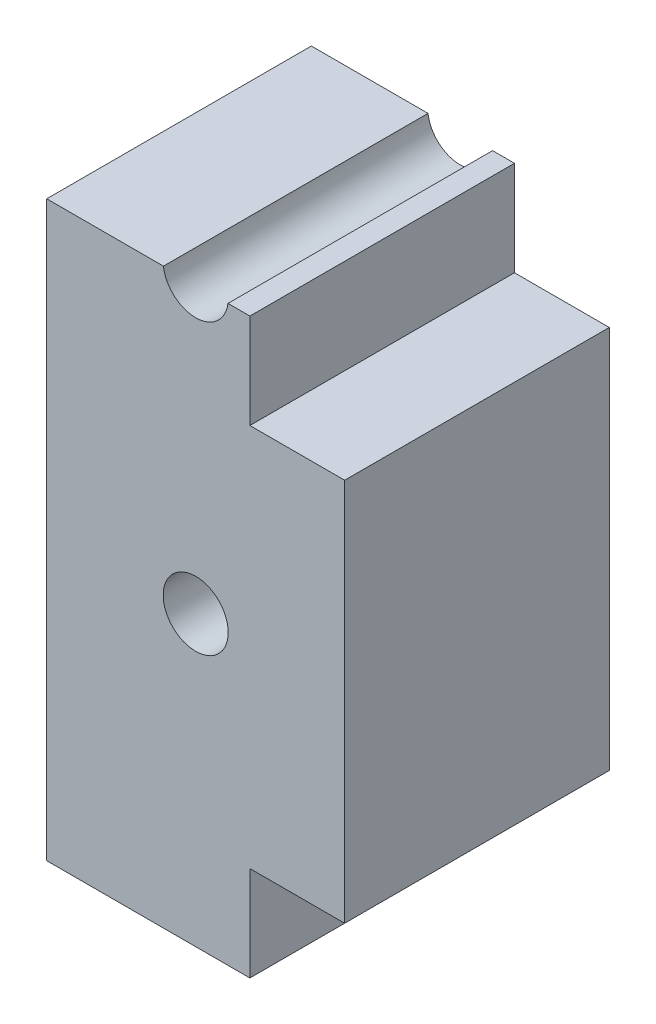
from build123d import *

# Parameters (mm, degrees)
SKETCH2_W           = 16.5
SKETCH2_H           = 31.75
BOSS_EXTRUDE1_DEPTH = 14.655
SKETCH5_W           = 5.25
SKETCH5_H           = 5.25
CUT_EXTRUDE2_DEPTH  = 15.655
SKETCH6_R           = 1.8
CUT_EXTRUDE3_DEPTH  = 15.655


with BuildPart() as part:
    # Sketch2 → Boss-Extrude1 (new body)
    with BuildSketch(Plane.XY):
        with Locations((0, -23.230249591)):
            Rectangle(SKETCH2_W, SKETCH2_H)
    extrude(amount=BOSS_EXTRUDE1_DEPTH)

    # Sketch5 → Cut-Extrude2 (cut, through all)
    with BuildSketch(Plane.XY.offset(14.655)):
        with Locations((5.625, -36.480249591)):
            Rectangle(SKETCH5_W, SKETCH5_H)
        with Locations((5.625, -9.980249591)):
            Rectangle(SKETCH5_W, SKETCH5_H)
    extrude(amount=-CUT_EXTRUDE2_DEPTH, mode=Mode.SUBTRACT)

    # Sketch6 → Cut-Extrude3 (cut, through all)
    with BuildSketch(Plane.XY.offset(14.655)):
        with Locations((0, -23.136715776)):
            Circle(SKETCH6_R)
        with Locations((0, -7.136715776)):
            Circle(SKETCH6_R)
    extrude(amount=-CUT_EXTRUDE3_DEPTH, mode=Mode.SUBTRACT)


solid = part.part
